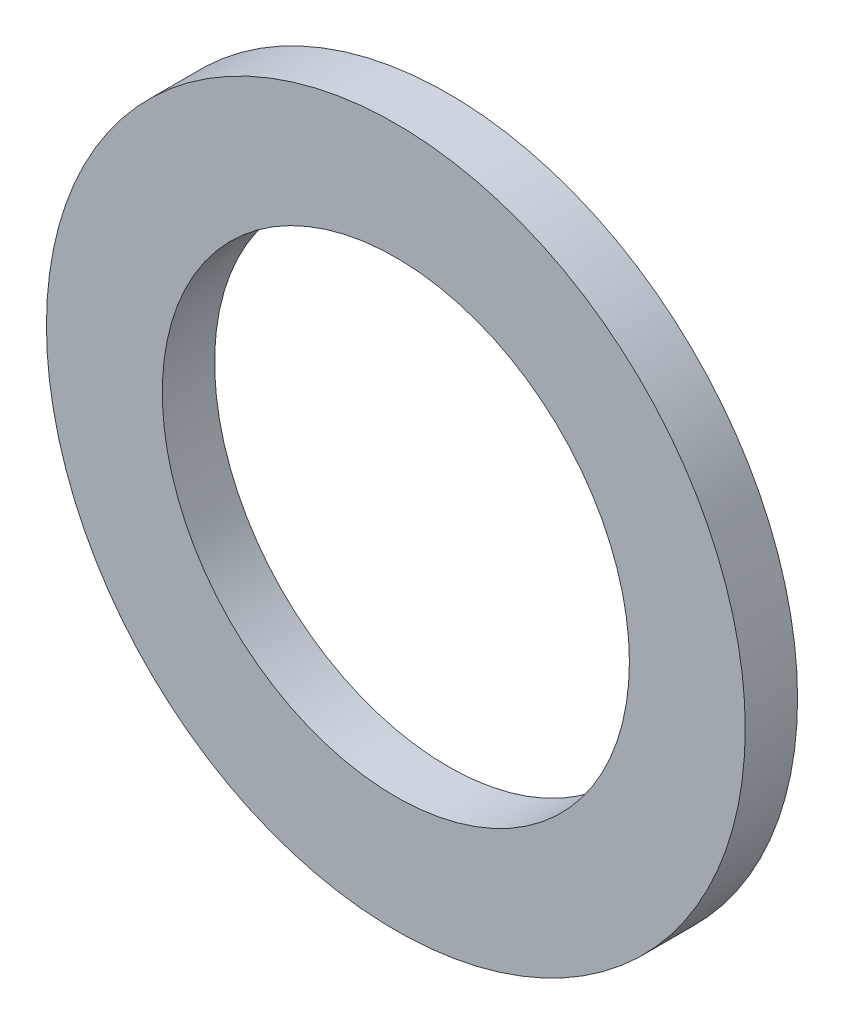
from build123d import *

# Parameters (mm, degrees)
SKETCH1_R           = 2.3749
SKETCH1_R_2         = 1.5875
BOSS_EXTRUDE1_DEPTH = 0.3556


with BuildPart() as part:
    # Sketch1 → Boss-Extrude1 (new body)
    with BuildSketch(Plane.XY):
        Circle(SKETCH1_R)
        Circle(SKETCH1_R_2, mode=Mode.SUBTRACT)
    extrude(amount=BOSS_EXTRUDE1_DEPTH)


solid = part.part
